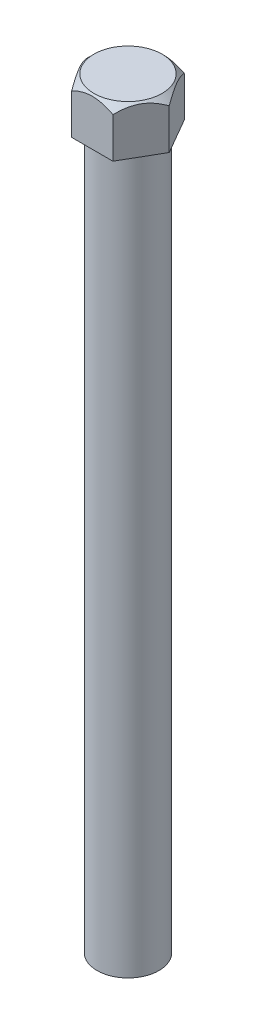
from build123d import *

# Parameters (mm, degrees)
SKETCH1_R           = 0.13
BOSS_EXTRUDE1_DEPTH = 3.2
BOSS_EXTRUDE2_DEPTH = 0.2


with BuildPart() as part:
    # Sketch1 → Boss-Extrude1 (new body)
    with BuildSketch(Plane(origin=(0, 0, 0), x_dir=(1, 0, 0), z_dir=(0, 1, 0))):
        Circle(SKETCH1_R)
    extrude(amount=BOSS_EXTRUDE1_DEPTH)

    # Sketch2 → Boss-Extrude2 (add)
    with BuildSketch(Plane(origin=(0, 3.2, 0), x_dir=(1, 0, 0), z_dir=(0, 1, 0))):
        Polygon((0.173205081, 0), (0.08660254, 0.15), (-0.08660254, 0.15), (-0.173205081, 0), (-0.08660254, -0.15), (0.08660254, -0.15), align=None)
    extrude(amount=-BOSS_EXTRUDE2_DEPTH)

    # Sketch3 → Cut-Revolve1 (revolve, cut)
    with BuildSketch(Plane.XY):
        Polygon((0.173205081, 3.2), (0.173205081, 3.17), (0.143205081, 3.2), align=None)
    revolve(axis=Axis((0, 0, 0), (0, 1, 0)), mode=Mode.SUBTRACT)


solid = part.part
